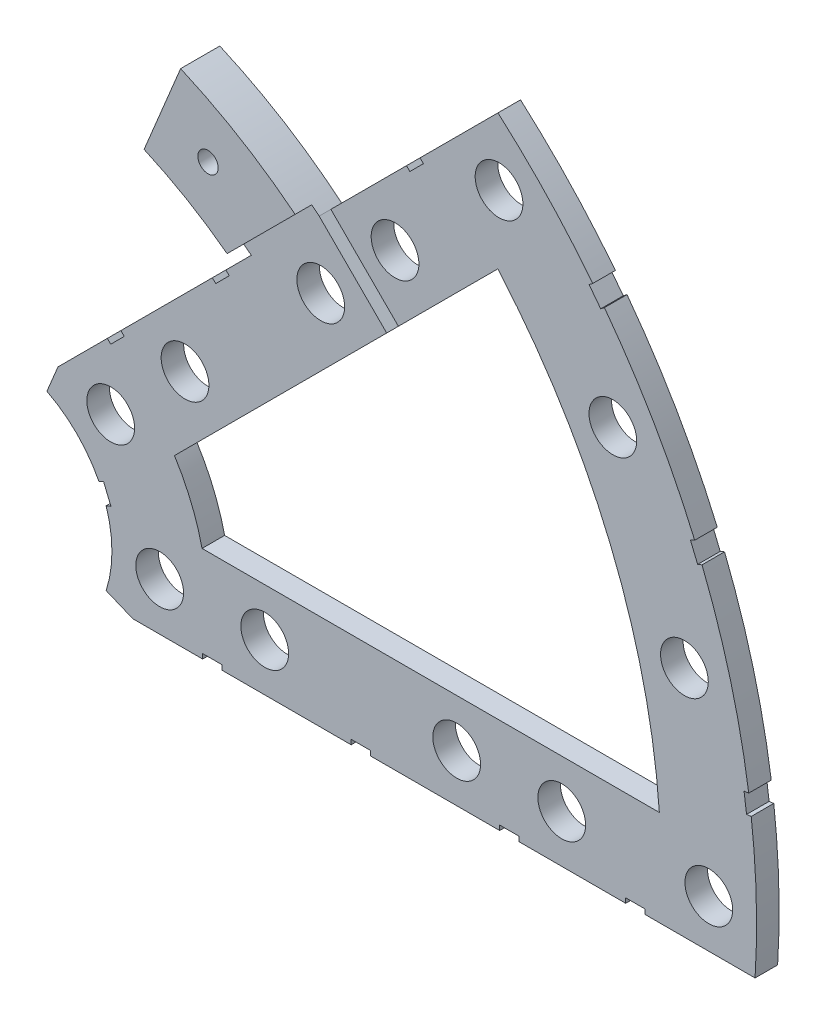
from build123d import *

# Parameters (mm, degrees)
BOSS_EXTRUDE1_DEPTH   = 3.000000096
SKETCH2_R             = 3.175
CUT_EXTRUDE1_DEPTH    = 4.000000096
SKETCH3_W             = 2.54
SKETCH3_H             = 0.635
CUT_EXTRUDE2_DEPTH    = 4.000000096
BOSS_EXTRUDE2_DEPTH   = 2.206999904
F_6_32_TAPPED_HOLE1_D = 2.7051


with BuildPart() as part:
    # Sketch1 → Boss-Extrude1 (new body)
    with BuildSketch(Plane.XY):
        with BuildLine():
            Line((27.218819563, 62.393373411), (22.357699804, 50.65759216))
            ThreePointArc((22.357699804, 50.65759216), (28.61353693, 47.405947816), (34.405475059, 43.38573118))
            Line((34.405475059, 43.38573118), (8.696654013, 17.676910134))
            Line((8.696654013, 17.676910134), (7.228954972, 14.133571205))
            ThreePointArc((7.228954972, 14.133571205), (14.666587579, 6.075099489), (15.105587123, -4.88230096))
            Line((15.105587123, -4.88230096), (18.648926052, -6.35))
            Line((18.648926052, -6.35), (101.401368334, -6.35))
            ThreePointArc((101.401368334, -6.35), (93.866160503, 38.880636728), (67.21146711, 76.191723231))
            Line((67.21146711, 76.191723231), (43.43415954, 52.414415661))
            ThreePointArc((43.43415954, 52.414415661), (35.677104191, 57.973626939), (27.218819563, 62.393373411))
        make_face()
        with BuildLine():
            Line((88.672924278, 6.35), (27.86051193, 6.35))
            ThreePointArc((27.86051193, 6.35), (26.399857642, 10.93517908), (24.190484974, 15.210228852))
            Line((24.190484974, 15.210228852), (67.191354125, 58.211098004))
            ThreePointArc((67.191354125, 58.211098004), (82.13289044, 34.020557137), (88.672924278, 6.35))
        make_face(mode=Mode.SUBTRACT)
    extrude(amount=BOSS_EXTRUDE1_DEPTH)

    # Sketch2 → Cut-Extrude1 (cut, through all)
    with BuildSketch(Plane.XY.offset(3.000000096)):
        with Locations((22.225, 0)):
            Circle(SKETCH2_R)
        with Locations((36.195, 0)):
            Circle(SKETCH2_R)
        with Locations((61.722, 0)):
            Circle(SKETCH2_R)
        with Locations((75.692, 0)):
            Circle(SKETCH2_R)
        with Locations((95.25, 0)):
            Circle(SKETCH2_R)
        with Locations((15.715448212, 15.715448212)):
            Circle(SKETCH2_R)
        with Locations((25.593729945, 25.593729945)):
            Circle(SKETCH2_R)
        with Locations((43.644044748, 43.644044748)):
            Circle(SKETCH2_R)
        with Locations((53.522326482, 53.522326482)):
            Circle(SKETCH2_R)
        with Locations((92.004434954, 24.652514046)):
            Circle(SKETCH2_R)
        with Locations((82.48891971, 47.625)):
            Circle(SKETCH2_R)
        with Locations((67.351920908, 67.351920908)):
            Circle(SKETCH2_R)
    extrude(amount=-CUT_EXTRUDE1_DEPTH, mode=Mode.SUBTRACT)

    # Sketch3 → Cut-Extrude2 (cut, through all)
    with BuildSketch(Plane.XY.offset(3.000000096)):
        Polygon((15.266435406, 24.246691527), (17.06248663, 26.042742751), (17.511499436, 25.593729945), (15.715448212, 23.797678721), align=None)
        Polygon((43.43415954, 52.414415661), (44.991083167, 53.971339288), (53.971339288, 44.991083167), (52.414415661, 43.43415954), align=None)
        with Locations((29.21, -6.0325)):
            Rectangle(SKETCH3_W, SKETCH3_H)
        with Locations((68.707, -6.0325)):
            Rectangle(SKETCH3_W, SKETCH3_H)
        Polygon((29.230733674, 38.210989795), (31.026784898, 40.007041019), (31.475797704, 39.558028213), (29.67974648, 37.761976989), align=None)
        Polygon((56.845021246, 65.825277367), (55.048970022, 64.029226143), (55.497982828, 63.580213337), (57.294034052, 65.376264561), align=None)
        with Locations((48.9585, -6.0325)):
            Rectangle(SKETCH3_W, SKETCH3_H)
        with Locations((85.471, -6.0325)):
            Rectangle(SKETCH3_W, SKETCH3_H)
        Polygon((99.935462164, 14.437711971), (100.266998693, 11.919442024), (101.526133667, 12.085210288), (101.194597138, 14.603480236), align=None)
        Polygon((93.765504959, 37.464305742), (94.938831965, 37.950313702), (93.966816047, 40.296967714), (92.793489041, 39.810959755), align=None)
        Polygon((79.327792988, 62.471156422), (80.874047017, 60.456038938), (81.88160576, 61.229165953), (80.33535173, 63.244283437), align=None)
        Polygon((13.593916116, 7.005422516), (14.565932035, 4.658768503), (15.739259041, 5.144776462), (14.767243123, 7.491430475), align=None)
    extrude(amount=-CUT_EXTRUDE2_DEPTH, mode=Mode.SUBTRACT)

    # Sketch4 → Boss-Extrude2 (add)
    with BuildSketch(Plane.XY.offset(3.000000096)):
        with BuildLine():
            Line((22.357699804, 50.65759216), (27.218819563, 62.393373411))
            ThreePointArc((27.218819563, 62.393373411), (35.13186657, 58.305652688), (42.443492672, 53.219800017))
            Line((42.443492672, 53.219800017), (33.393246405, 44.169553751))
            ThreePointArc((33.393246405, 44.169553751), (28.063600293, 47.73355971), (22.357699804, 50.65759216))
        make_face()
    extrude(amount=BOSS_EXTRUDE2_DEPTH)

    # #6-32 Tapped Hole1 (through all)
    with Locations(Plane(origin=(0, 0, 0), x_dir=(-1, 0, 0), z_dir=(0, 0, -1))):
        with Locations((-30.861, 53.452819972)):
            Hole(F_6_32_TAPPED_HOLE1_D / 2)


solid = part.part
